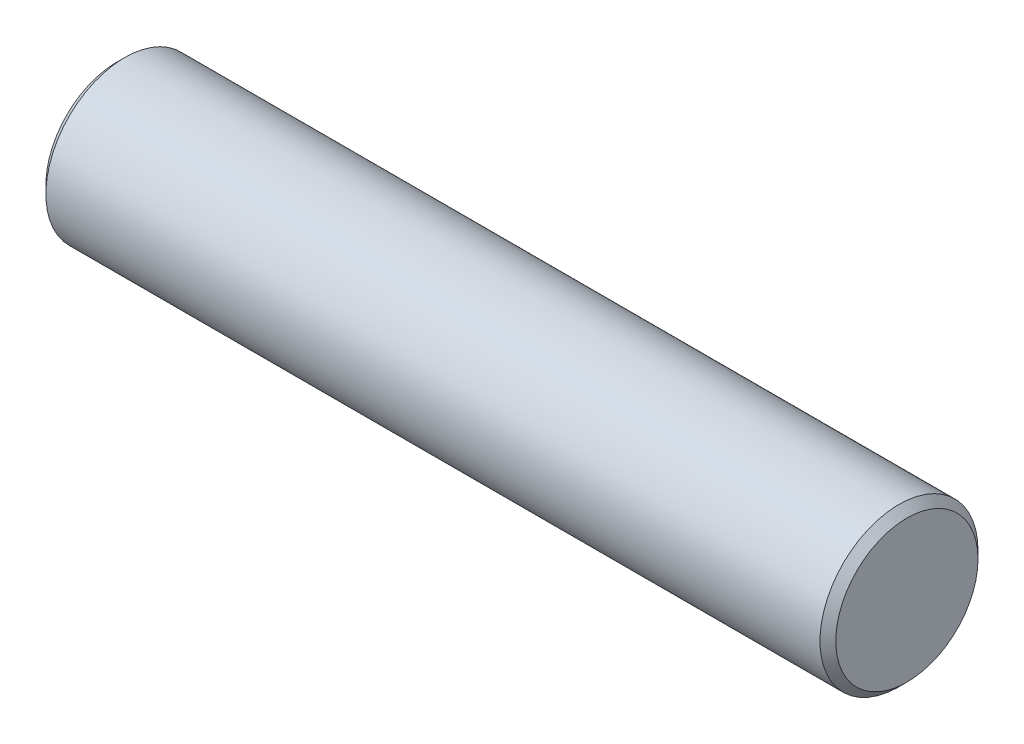
from build123d import *

# Parameters (mm, degrees)
SKETCH_1_R      = 10
EXTRUDE_1_DEPTH = 100
CHAMFER_1_SIZE  = 1


with BuildPart() as part:
    # Эскиз1 → Бобышка-Вытянуть1 (new body)
    with BuildSketch(Plane(origin=(0, 0, 0), x_dir=(0, 0, -1), z_dir=(1, 0, 0))):
        Circle(SKETCH_1_R)
    extrude(amount=EXTRUDE_1_DEPTH)

    # Фаска1
    chamfer_1_edges = [part.edges().sort_by_distance(p)[0] for p in [
        (0, 0, 10),
        (100, 0, 10),
    ]]
    chamfer(chamfer_1_edges, length=CHAMFER_1_SIZE)


solid = part.part
